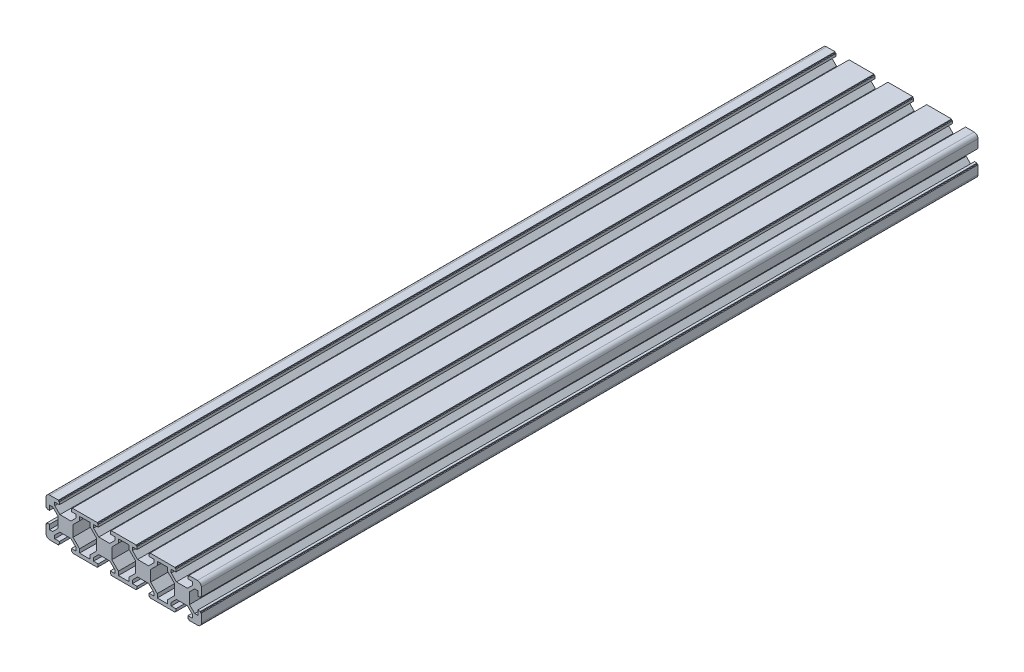
from build123d import *

# Parameters (mm, degrees)
EXTRUDE_1_DEPTH = 400
FILLET_1_R      = 2


with BuildPart() as part:
    # 草图1 → 凸台-拉伸1 (new body)
    with BuildSketch(Plane.XY):
        Polygon((-2.839339828, 3.9), (2.839339828, 3.9), (5.5, 6.560660172), (5.5, 8.2), (3.1, 8.2), (3.1, 9.5), (3.6, 9.5), (3.6, 10), (7.3, 10), (10, 10), (12.7, 10), (16.4, 10), (16.4, 9.5), (16.9, 9.5), (16.9, 8.2), (14.5, 8.2), (14.5, 6.560660172), (17.160660172, 3.9), (22.839339828, 3.9), (25.5, 6.560660172), (25.5, 8.2), (23.1, 8.2), (23.1, 9.5), (23.6, 9.5), (23.6, 10), (27.3, 10), (30, 10), (32.7, 10), (36.4, 10), (36.4, 9.5), (36.9, 9.5), (36.9, 8.2), (34.5, 8.2), (34.5, 6.560660172), (37.160660172, 3.9), (42.839339828, 3.9), (45.5, 6.560660172), (45.5, 8.2), (43.1, 8.2), (43.1, 9.5), (43.6, 9.5), (43.6, 10), (47.3, 10), (50, 10), (52.7, 10), (56.4, 10), (56.4, 9.5), (56.9, 9.5), (56.9, 8.2), (54.5, 8.2), (54.5, 6.560660172), (57.160660172, 3.9), (62.839339828, 3.9), (65.5, 6.560660172), (65.5, 8.2), (63.1, 8.2), (63.1, 9.5), (63.6, 9.5), (63.6, 10), (70, 10), (70, 3.6), (69.5, 3.6), (69.5, 3.1), (68.2, 3.1), (68.2, 5.5), (66.560660172, 5.5), (63.9, 2.839339828), (63.9, -2.839339828), (66.560660172, -5.5), (68.2, -5.5), (68.2, -3.1), (69.5, -3.1), (69.5, -3.6), (70, -3.6), (70, -10), (63.6, -10), (63.6, -9.5), (63.1, -9.5), (63.1, -8.2), (65.5, -8.2), (65.5, -6.560660172), (62.839339828, -3.9), (57.160660172, -3.9), (54.5, -6.560660172), (54.5, -8.2), (56.9, -8.2), (56.9, -9.5), (56.4, -9.5), (56.4, -10), (52.7, -10), (50, -10), (47.3, -10), (43.6, -10), (43.6, -9.5), (43.1, -9.5), (43.1, -8.2), (45.5, -8.2), (45.5, -6.560660172), (42.839339828, -3.9), (37.160660172, -3.9), (34.5, -6.560660172), (34.5, -8.2), (36.9, -8.2), (36.9, -9.5), (36.4, -9.5), (36.4, -10), (32.7, -10), (30, -10), (27.3, -10), (23.6, -10), (23.6, -9.5), (23.1, -9.5), (23.1, -8.2), (25.5, -8.2), (25.5, -6.560660172), (22.839339828, -3.9), (17.160660172, -3.9), (14.5, -6.560660172), (14.5, -8.2), (16.9, -8.2), (16.9, -9.5), (16.4, -9.5), (16.4, -10), (12.7, -10), (10, -10), (7.3, -10), (3.6, -10), (3.6, -9.5), (3.1, -9.5), (3.1, -8.2), (5.5, -8.2), (5.5, -6.560660172), (2.839339828, -3.9), (-2.839339828, -3.9), (-5.5, -6.560660172), (-5.5, -8.2), (-3.1, -8.2), (-3.1, -9.5), (-3.6, -9.5), (-3.6, -10), (-10, -10), (-10, -3.6), (-9.5, -3.6), (-9.5, -3.1), (-8.2, -3.1), (-8.2, -5.5), (-6.560660172, -5.5), (-3.9, -2.839339828), (-3.9, 2.839339828), (-6.560660172, 5.5), (-8.2, 5.5), (-8.2, 3.1), (-9.5, 3.1), (-9.5, 3.6), (-10, 3.6), (-10, 10), (-3.6, 10), (-3.6, 9.5), (-3.1, 9.5), (-3.1, 8.2), (-5.5, 8.2), (-5.5, 6.560660172), align=None)
        Polygon((3.9, 2.839339828), (3.9, -2.839339828), (7.3, -6.239339828), (7.3, -8.2), (10, -8.2), (12.7, -8.2), (12.7, -6.239339828), (16.1, -2.839339828), (16.1, 2.839339828), (12.7, 6.239339828), (12.7, 8.2), (10, 8.2), (7.3, 8.2), (7.3, 6.239339828), align=None, mode=Mode.SUBTRACT)
        Polygon((23.9, 2.839339828), (23.9, -2.839339828), (27.3, -6.239339828), (27.3, -8.2), (30, -8.2), (32.7, -8.2), (32.7, -6.239339828), (36.1, -2.839339828), (36.1, 2.839339828), (32.7, 6.239339828), (32.7, 8.2), (30, 8.2), (27.3, 8.2), (27.3, 6.239339828), align=None, mode=Mode.SUBTRACT)
        Polygon((43.9, 2.839339828), (43.9, -2.839339828), (47.3, -6.239339828), (47.3, -8.2), (50, -8.2), (52.7, -8.2), (52.7, -6.239339828), (56.1, -2.839339828), (56.1, 2.839339828), (52.7, 6.239339828), (52.7, 8.2), (50, 8.2), (47.3, 8.2), (47.3, 6.239339828), align=None, mode=Mode.SUBTRACT)
    extrude(amount=EXTRUDE_1_DEPTH)

    # 圆角1
    fillet_1_edges = [part.edges().sort_by_distance(p)[0] for p in [
        (-10, 10, 200),
        (70, 10, 200),
        (70, -10, 200),
        (-10, -10, 200),
    ]]
    fillet(fillet_1_edges, radius=FILLET_1_R)


solid = part.part
